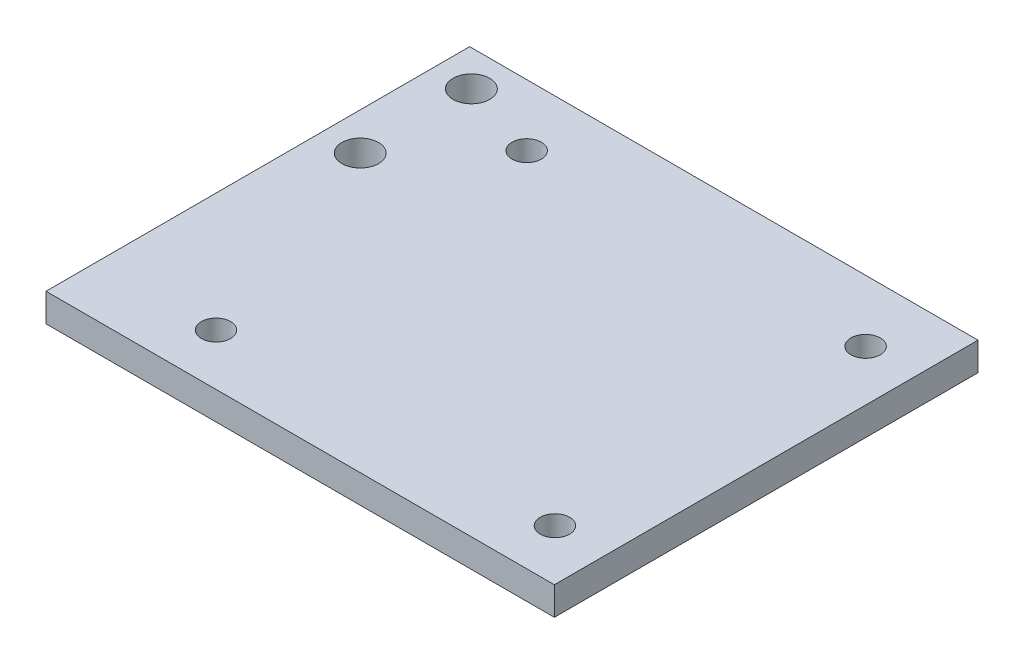
from build123d import *

# Parameters (mm, degrees)
SKETCH4_W           = 45.72
SKETCH4_H           = 38.1
BOSS_EXTRUDE1_DEPTH = 2.54
SKETCH5_R           = 1.65
SKETCH5_R_2         = 1.32
CUT_EXTRUDE1_DEPTH  = 2.54


with BuildPart() as part:
    # Sketch4 → Boss-Extrude1 (new body)
    with BuildSketch(Plane(origin=(0, 0, 0), x_dir=(1, 0, 0), z_dir=(0, 1, 0))):
        with Locations((22.86, 19.05)):
            Rectangle(SKETCH4_W, SKETCH4_H)
    extrude(amount=BOSS_EXTRUDE1_DEPTH)

    # Sketch5 → Cut-Extrude1 (cut)
    with BuildSketch(Plane.XZ):
        with Locations((3.3655, -24.892)):
            Circle(SKETCH5_R)
        with Locations((3.3655, -34.892)):
            Circle(SKETCH5_R)
        with Locations((10.668, -4.6228)):
            Circle(SKETCH5_R_2)
        with Locations((10.668, -32.5628)):
            Circle(SKETCH5_R_2)
        with Locations((41.148, -4.6228)):
            Circle(SKETCH5_R_2)
        with Locations((41.148, -32.5628)):
            Circle(SKETCH5_R_2)
    extrude(amount=-CUT_EXTRUDE1_DEPTH, mode=Mode.SUBTRACT)


solid = part.part
